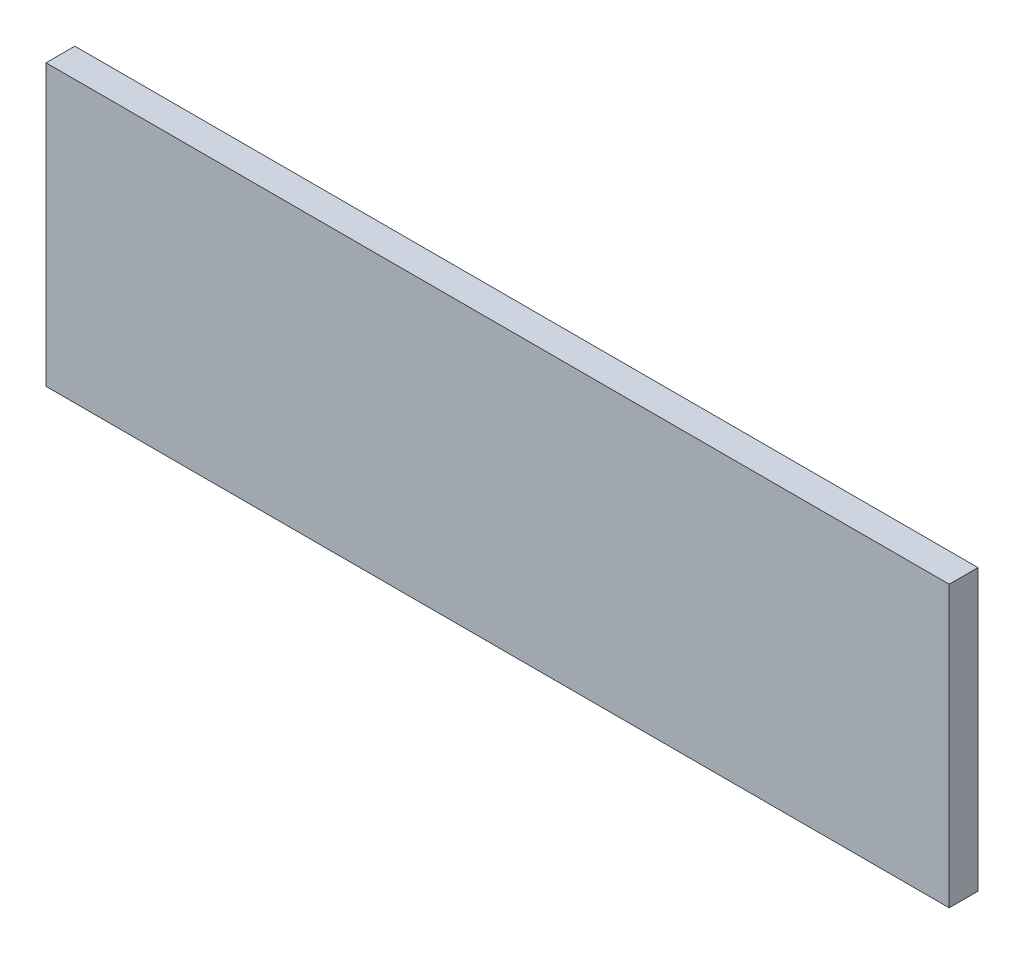
from build123d import *

# Parameters (mm, degrees)
SKETCH1_W           = 564
SKETCH1_H           = 175
BOSS_EXTRUDE1_DEPTH = 18


with BuildPart() as part:
    # Sketch1 → Boss-Extrude1 (new body)
    with BuildSketch(Plane.XY):
        Rectangle(SKETCH1_W, SKETCH1_H)
    extrude(amount=BOSS_EXTRUDE1_DEPTH)


solid = part.part
